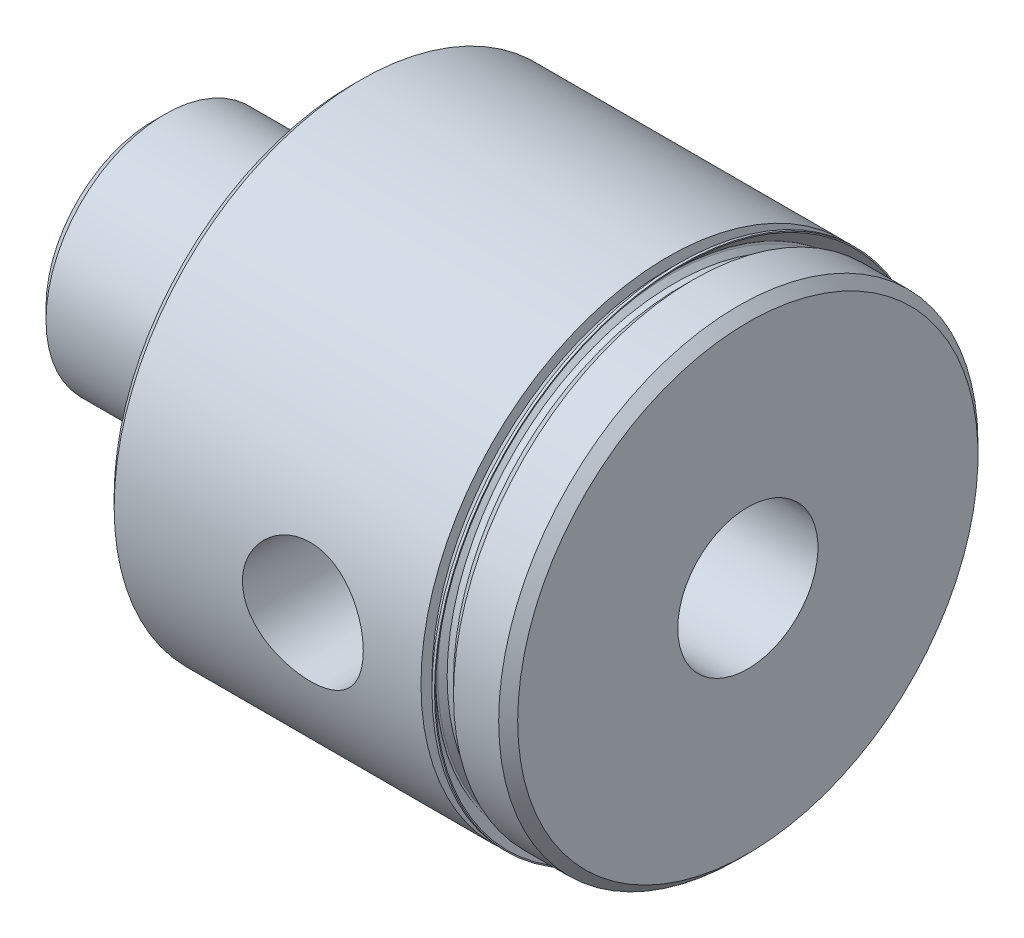
from build123d import *

# Parameters (mm, degrees)
HOLE1_D           = 11.2268
HOLE1_DEPTH       = 47.625
HOLE1_CSINK_D     = 12.7508
HOLE1_CSINK_ANGLE = 90


with BuildPart() as part:
    # Sketch1 → Revolve1 (revolve)
    with BuildSketch(Plane.XY):
        with BuildLine():
            Line((0, 0), (0, 8.58901))
            Line((0, 8.58901), (0.93599, 9.525))
            Line((0.93599, 9.525), (9.310047461, 9.525))
            Line((9.310047461, 9.525), (10.262333187, 8.610821042))
            ThreePointArc((10.262333187, 8.610821042), (10.619173954, 8.380210754), (11.0363, 8.29945))
            Line((11.0363, 8.29945), (12.3698, 8.29945))
            ThreePointArc((12.3698, 8.29945), (13.160062539, 8.626787461), (13.4874, 9.41705))
            Line((13.4874, 9.41705), (13.4874, 9.49325))
            Line((13.4874, 9.49325), (15.875, 9.49325))
            Line((15.875, 9.49325), (15.875, 0))
            Line((15.875, 0), (0, 0))
        make_face()
    revolve(axis=Axis((15.875, 0, 0), (-1, 0, 0)))

    # Sketch2 → Revolve2 (revolve)
    with BuildSketch(Plane.XY):
        Polygon((15.875, 0), (15.875, 19.00555), (16.637, 19.76755), (41.2115, 19.76755), (41.2115, 18.18005), (42.2275, 18.18005), (43.2435, 19.19605), (46.863, 19.19605), (47.625, 18.43405), (47.625, 0), align=None)
    revolve(axis=Axis((47.625, 0, 0), (-1, 0, 0)))

    # Hole1
    with Locations(Plane.ZY):
        with Locations((0, 0)):
            CounterSinkHole(HOLE1_D / 2, HOLE1_CSINK_D / 2, depth=HOLE1_DEPTH, counter_sink_angle=HOLE1_CSINK_ANGLE)

    # Sketch5 → Cut-Revolve1 (revolve, cut)
    with BuildSketch(Plane(origin=(0, 0, 0), x_dir=(1, 0, 0), z_dir=(0, 1, 0))):
        Polygon((31.75, 0), (34.925, 0), (34.925, -7.768124148), (36.256425852, -9.09955), (36.589475925, -19.76755), (31.75, -19.76755), align=None)
    revolve(axis=Axis((31.75, 0, 19.76755), (0, 0, -1)), mode=Mode.SUBTRACT)

    # Sketch6 → Revolve3 (revolve)
    with BuildSketch(Plane.XY):
        with BuildLine():
            Line((41.2115, 17.92605), (42.2275, 17.92605))
            Line((42.2275, 17.92605), (42.2275, 18.18005))
            Line((42.2275, 18.18005), (41.7195, 18.18005))
            Line((41.7195, 18.18005), (41.344882072, 18.554667928))
            ThreePointArc((41.344882072, 18.554667928), (41.307684633, 18.64447049), (41.344882072, 18.734273051))
            Line((41.344882072, 18.734273051), (42.293990825, 19.683381804))
            Line((42.293990825, 19.683381804), (42.293990825, 19.76755))
            Line((42.293990825, 19.76755), (42.090790825, 19.76755))
            Line((42.090790825, 19.76755), (41.2115, 18.888259175))
            Line((41.2115, 18.888259175), (41.2115, 17.92605))
        make_face()
    revolve(axis=Axis((42.2275, 0, 0), (-1, 0, 0)))


solid = part.part
